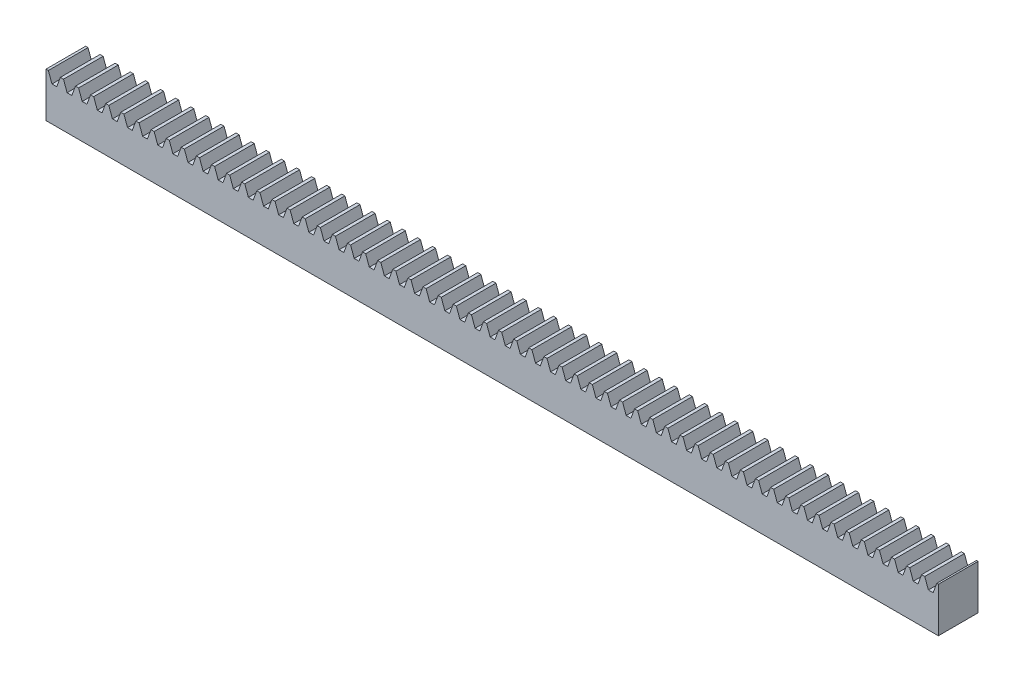
from build123d import *

# Parameters (mm, degrees)
SKETCH1_W           = 90
SKETCH1_H           = 4
BOSS_EXTRUDE1_DEPTH = 4.5
CUT_EXTRUDE1_DEPTH  = 5


with BuildPart() as part:
    # Sketch1 → Boss-Extrude1 (new body)
    with BuildSketch(Plane(origin=(0, 0, 0), x_dir=(1, 0, 0), z_dir=(0, 1, 0))):
        with Locations((45, 2)):
            Rectangle(SKETCH1_W, SKETCH1_H)
    extrude(amount=BOSS_EXTRUDE1_DEPTH)

    # Sketch2 → Cut-Extrude1 (cut, through all)
    with BuildSketch(Plane.XY):
        Polygon((0.239013956, 4.5), (0.60298419, 3.5), (0.841998146, 3.5), (1.081012101, 3.5), (1.444982335, 4.5), align=None)
        Polygon((1.763013956, 4.5), (2.12698419, 3.5), (2.365998146, 3.5), (2.605012101, 3.5), (2.968982335, 4.5), align=None)
        Polygon((3.287013956, 4.5), (3.65098419, 3.5), (3.889998146, 3.5), (4.129012101, 3.5), (4.492982335, 4.5), align=None)
        Polygon((4.811013956, 4.5), (5.17498419, 3.5), (5.413998146, 3.5), (5.653012101, 3.5), (6.016982335, 4.5), align=None)
        Polygon((6.335013956, 4.5), (6.69898419, 3.5), (6.937998146, 3.5), (7.177012101, 3.5), (7.540982335, 4.5), align=None)
        Polygon((7.859013956, 4.5), (8.22298419, 3.5), (8.461998146, 3.5), (8.701012101, 3.5), (9.064982335, 4.5), align=None)
        Polygon((9.383013956, 4.5), (9.74698419, 3.5), (9.985998146, 3.5), (10.225012101, 3.5), (10.588982335, 4.5), align=None)
        Polygon((10.907013956, 4.5), (11.27098419, 3.5), (11.509998146, 3.5), (11.749012101, 3.5), (12.112982335, 4.5), align=None)
        Polygon((12.431013956, 4.5), (12.79498419, 3.5), (13.033998146, 3.5), (13.273012101, 3.5), (13.636982335, 4.5), align=None)
        Polygon((13.955013956, 4.5), (14.31898419, 3.5), (14.557998146, 3.5), (14.797012101, 3.5), (15.160982335, 4.5), align=None)
        Polygon((15.479013956, 4.5), (15.84298419, 3.5), (16.081998146, 3.5), (16.321012101, 3.5), (16.684982335, 4.5), align=None)
        Polygon((17.003013956, 4.5), (17.36698419, 3.5), (17.605998146, 3.5), (17.845012101, 3.5), (18.208982335, 4.5), align=None)
        Polygon((18.527013956, 4.5), (18.89098419, 3.5), (19.129998146, 3.5), (19.369012101, 3.5), (19.732982335, 4.5), align=None)
        Polygon((20.051013956, 4.5), (20.41498419, 3.5), (20.653998146, 3.5), (20.893012101, 3.5), (21.256982335, 4.5), align=None)
        Polygon((21.575013956, 4.5), (21.93898419, 3.5), (22.177998146, 3.5), (22.417012101, 3.5), (22.780982335, 4.5), align=None)
        Polygon((23.099013956, 4.5), (23.46298419, 3.5), (23.701998146, 3.5), (23.941012101, 3.5), (24.304982335, 4.5), align=None)
        Polygon((24.623013956, 4.5), (24.98698419, 3.5), (25.225998146, 3.5), (25.465012101, 3.5), (25.828982335, 4.5), align=None)
        Polygon((26.147013956, 4.5), (26.51098419, 3.5), (26.749998146, 3.5), (26.989012101, 3.5), (27.352982335, 4.5), align=None)
        Polygon((27.671013956, 4.5), (28.03498419, 3.5), (28.273998146, 3.5), (28.513012101, 3.5), (28.876982335, 4.5), align=None)
        Polygon((29.195013956, 4.5), (29.55898419, 3.5), (29.797998146, 3.5), (30.037012101, 3.5), (30.400982335, 4.5), align=None)
        Polygon((30.719013956, 4.5), (31.08298419, 3.5), (31.321998146, 3.5), (31.561012101, 3.5), (31.924982335, 4.5), align=None)
        Polygon((32.243013956, 4.5), (32.60698419, 3.5), (32.845998146, 3.5), (33.085012101, 3.5), (33.448982335, 4.5), align=None)
        Polygon((33.767013956, 4.5), (34.13098419, 3.5), (34.369998146, 3.5), (34.609012101, 3.5), (34.972982335, 4.5), align=None)
        Polygon((35.291013956, 4.5), (35.65498419, 3.5), (35.893998146, 3.5), (36.133012101, 3.5), (36.496982335, 4.5), align=None)
        Polygon((36.815013956, 4.5), (37.17898419, 3.5), (37.417998146, 3.5), (37.657012101, 3.5), (38.020982335, 4.5), align=None)
        Polygon((38.339013956, 4.5), (38.70298419, 3.5), (38.941998146, 3.5), (39.181012101, 3.5), (39.544982335, 4.5), align=None)
        Polygon((39.863013956, 4.5), (40.22698419, 3.5), (40.465998146, 3.5), (40.705012101, 3.5), (41.068982335, 4.5), align=None)
        Polygon((41.387013956, 4.5), (41.75098419, 3.5), (41.989998146, 3.5), (42.229012101, 3.5), (42.592982335, 4.5), align=None)
        Polygon((42.911013956, 4.5), (43.27498419, 3.5), (43.513998146, 3.5), (43.753012101, 3.5), (44.116982335, 4.5), align=None)
        Polygon((44.435013956, 4.5), (44.79898419, 3.5), (45.037998146, 3.5), (45.277012101, 3.5), (45.640982335, 4.5), align=None)
        Polygon((45.959013956, 4.5), (46.32298419, 3.5), (46.561998146, 3.5), (46.801012101, 3.5), (47.164982335, 4.5), align=None)
        Polygon((47.483013956, 4.5), (47.84698419, 3.5), (48.085998146, 3.5), (48.325012101, 3.5), (48.688982335, 4.5), align=None)
        Polygon((49.007013956, 4.5), (49.37098419, 3.5), (49.609998146, 3.5), (49.849012101, 3.5), (50.212982335, 4.5), align=None)
        Polygon((50.531013956, 4.5), (50.89498419, 3.5), (51.133998146, 3.5), (51.373012101, 3.5), (51.736982335, 4.5), align=None)
        Polygon((52.055013956, 4.5), (52.41898419, 3.5), (52.657998146, 3.5), (52.897012101, 3.5), (53.260982335, 4.5), align=None)
        Polygon((53.579013956, 4.5), (53.94298419, 3.5), (54.181998146, 3.5), (54.421012101, 3.5), (54.784982335, 4.5), align=None)
        Polygon((55.103013956, 4.5), (55.46698419, 3.5), (55.705998146, 3.5), (55.945012101, 3.5), (56.308982335, 4.5), align=None)
        Polygon((56.627013956, 4.5), (56.99098419, 3.5), (57.229998146, 3.5), (57.469012101, 3.5), (57.832982335, 4.5), align=None)
        Polygon((58.151013956, 4.5), (58.51498419, 3.5), (58.753998146, 3.5), (58.993012101, 3.5), (59.356982335, 4.5), align=None)
        Polygon((59.675013956, 4.5), (60.03898419, 3.5), (60.277998146, 3.5), (60.517012101, 3.5), (60.880982335, 4.5), align=None)
        Polygon((61.199013956, 4.5), (61.56298419, 3.5), (61.801998146, 3.5), (62.041012101, 3.5), (62.404982335, 4.5), align=None)
        Polygon((62.723013956, 4.5), (63.08698419, 3.5), (63.325998146, 3.5), (63.565012101, 3.5), (63.928982335, 4.5), align=None)
        Polygon((64.247013956, 4.5), (64.61098419, 3.5), (64.849998146, 3.5), (65.089012101, 3.5), (65.452982335, 4.5), align=None)
        Polygon((65.771013956, 4.5), (66.13498419, 3.5), (66.373998146, 3.5), (66.613012101, 3.5), (66.976982335, 4.5), align=None)
        Polygon((67.295013956, 4.5), (67.65898419, 3.5), (67.897998146, 3.5), (68.137012101, 3.5), (68.500982335, 4.5), align=None)
        Polygon((68.819013956, 4.5), (69.18298419, 3.5), (69.421998146, 3.5), (69.661012101, 3.5), (70.024982335, 4.5), align=None)
        Polygon((70.343013956, 4.5), (70.70698419, 3.5), (70.945998146, 3.5), (71.185012101, 3.5), (71.548982335, 4.5), align=None)
        Polygon((71.867013956, 4.5), (72.23098419, 3.5), (72.469998146, 3.5), (72.709012101, 3.5), (73.072982335, 4.5), align=None)
        Polygon((73.391013956, 4.5), (73.75498419, 3.5), (73.993998146, 3.5), (74.233012101, 3.5), (74.596982335, 4.5), align=None)
        Polygon((74.915013956, 4.5), (75.27898419, 3.5), (75.517998146, 3.5), (75.757012101, 3.5), (76.120982335, 4.5), align=None)
        Polygon((76.439013956, 4.5), (76.80298419, 3.5), (77.041998146, 3.5), (77.281012101, 3.5), (77.644982335, 4.5), align=None)
        Polygon((77.963013956, 4.5), (78.32698419, 3.5), (78.565998146, 3.5), (78.805012101, 3.5), (79.168982335, 4.5), align=None)
        Polygon((79.487013956, 4.5), (79.85098419, 3.5), (80.089998146, 3.5), (80.329012101, 3.5), (80.692982335, 4.5), align=None)
        Polygon((81.011013956, 4.5), (81.37498419, 3.5), (81.613998146, 3.5), (81.853012101, 3.5), (82.216982335, 4.5), align=None)
        Polygon((82.535013956, 4.5), (82.89898419, 3.5), (83.137998146, 3.5), (83.377012101, 3.5), (83.740982335, 4.5), align=None)
        Polygon((84.059013956, 4.5), (84.42298419, 3.5), (84.661998146, 3.5), (84.901012101, 3.5), (85.264982335, 4.5), align=None)
        Polygon((85.583013956, 4.5), (85.94698419, 3.5), (86.185998146, 3.5), (86.425012101, 3.5), (86.788982335, 4.5), align=None)
        Polygon((87.107013956, 4.5), (87.47098419, 3.5), (87.709998146, 3.5), (87.949012101, 3.5), (88.312982335, 4.5), align=None)
        Polygon((88.631013956, 4.5), (88.99498419, 3.5), (89.233998146, 3.5), (89.473012101, 3.5), (89.836982335, 4.5), align=None)
        Polygon((90.155013956, 4.5), (90.51898419, 3.5), (90.757998146, 3.5), (90.997012101, 3.5), (91.360982335, 4.5), align=None)
        Polygon((91.679013956, 4.5), (92.04298419, 3.5), (92.281998146, 3.5), (92.521012101, 3.5), (92.884982335, 4.5), align=None)
        Polygon((93.203013956, 4.5), (93.56698419, 3.5), (93.805998146, 3.5), (94.045012101, 3.5), (94.408982335, 4.5), align=None)
        Polygon((94.727013956, 4.5), (95.09098419, 3.5), (95.329998146, 3.5), (95.569012101, 3.5), (95.932982335, 4.5), align=None)
        Polygon((96.251013956, 4.5), (96.61498419, 3.5), (96.853998146, 3.5), (97.093012101, 3.5), (97.456982335, 4.5), align=None)
        Polygon((97.775013956, 4.5), (98.13898419, 3.5), (98.377998146, 3.5), (98.617012101, 3.5), (98.980982335, 4.5), align=None)
        Polygon((99.299013956, 4.5), (99.66298419, 3.5), (99.901998146, 3.5), (100.141012101, 3.5), (100.504982335, 4.5), align=None)
        Polygon((100.823013956, 4.5), (101.18698419, 3.5), (101.425998146, 3.5), (101.665012101, 3.5), (102.028982335, 4.5), align=None)
        Polygon((102.347013956, 4.5), (102.71098419, 3.5), (102.949998146, 3.5), (103.189012101, 3.5), (103.552982335, 4.5), align=None)
        Polygon((103.871013956, 4.5), (104.23498419, 3.5), (104.473998146, 3.5), (104.713012101, 3.5), (105.076982335, 4.5), align=None)
        Polygon((105.395013956, 4.5), (105.75898419, 3.5), (105.997998146, 3.5), (106.237012101, 3.5), (106.600982335, 4.5), align=None)
        Polygon((106.919013956, 4.5), (107.28298419, 3.5), (107.521998146, 3.5), (107.761012101, 3.5), (108.124982335, 4.5), align=None)
        Polygon((108.443013956, 4.5), (108.80698419, 3.5), (109.045998146, 3.5), (109.285012101, 3.5), (109.648982335, 4.5), align=None)
        Polygon((109.967013956, 4.5), (110.33098419, 3.5), (110.569998146, 3.5), (110.809012101, 3.5), (111.172982335, 4.5), align=None)
        Polygon((111.491013956, 4.5), (111.85498419, 3.5), (112.093998146, 3.5), (112.333012101, 3.5), (112.696982335, 4.5), align=None)
        Polygon((113.015013956, 4.5), (113.37898419, 3.5), (113.617998146, 3.5), (113.857012101, 3.5), (114.220982335, 4.5), align=None)
        Polygon((114.539013956, 4.5), (114.90298419, 3.5), (115.141998146, 3.5), (115.381012101, 3.5), (115.744982335, 4.5), align=None)
        Polygon((116.063013956, 4.5), (116.42698419, 3.5), (116.665998146, 3.5), (116.905012101, 3.5), (117.268982335, 4.5), align=None)
        Polygon((117.587013956, 4.5), (117.95098419, 3.5), (118.189998146, 3.5), (118.429012101, 3.5), (118.792982335, 4.5), align=None)
        Polygon((119.111013956, 4.5), (119.47498419, 3.5), (119.713998146, 3.5), (119.953012101, 3.5), (120.316982335, 4.5), align=None)
        Polygon((120.635013956, 4.5), (120.99898419, 3.5), (121.237998146, 3.5), (121.477012101, 3.5), (121.840982335, 4.5), align=None)
        Polygon((122.159013956, 4.5), (122.52298419, 3.5), (122.761998146, 3.5), (123.001012101, 3.5), (123.364982335, 4.5), align=None)
        Polygon((123.683013956, 4.5), (124.04698419, 3.5), (124.285998146, 3.5), (124.525012101, 3.5), (124.888982335, 4.5), align=None)
        Polygon((125.207013956, 4.5), (125.57098419, 3.5), (125.809998146, 3.5), (126.049012101, 3.5), (126.412982335, 4.5), align=None)
        Polygon((126.731013956, 4.5), (127.09498419, 3.5), (127.333998146, 3.5), (127.573012101, 3.5), (127.936982335, 4.5), align=None)
        Polygon((128.255013956, 4.5), (128.61898419, 3.5), (128.857998146, 3.5), (129.097012101, 3.5), (129.460982335, 4.5), align=None)
        Polygon((129.779013956, 4.5), (130.14298419, 3.5), (130.381998146, 3.5), (130.621012101, 3.5), (130.984982335, 4.5), align=None)
        Polygon((131.303013956, 4.5), (131.66698419, 3.5), (131.905998146, 3.5), (132.145012101, 3.5), (132.508982335, 4.5), align=None)
        Polygon((132.827013956, 4.5), (133.19098419, 3.5), (133.429998146, 3.5), (133.669012101, 3.5), (134.032982335, 4.5), align=None)
        Polygon((134.351013956, 4.5), (134.71498419, 3.5), (134.953998146, 3.5), (135.193012101, 3.5), (135.556982335, 4.5), align=None)
        Polygon((135.875013956, 4.5), (136.23898419, 3.5), (136.477998146, 3.5), (136.717012101, 3.5), (137.080982335, 4.5), align=None)
        Polygon((137.399013956, 4.5), (137.76298419, 3.5), (138.001998146, 3.5), (138.241012101, 3.5), (138.604982335, 4.5), align=None)
        Polygon((138.923013956, 4.5), (139.28698419, 3.5), (139.525998146, 3.5), (139.765012101, 3.5), (140.128982335, 4.5), align=None)
        Polygon((140.447013956, 4.5), (140.81098419, 3.5), (141.049998146, 3.5), (141.289012101, 3.5), (141.652982335, 4.5), align=None)
        Polygon((141.971013956, 4.5), (142.33498419, 3.5), (142.573998146, 3.5), (142.813012101, 3.5), (143.176982335, 4.5), align=None)
        Polygon((143.495013956, 4.5), (143.85898419, 3.5), (144.097998146, 3.5), (144.337012101, 3.5), (144.700982335, 4.5), align=None)
        Polygon((145.019013956, 4.5), (145.38298419, 3.5), (145.621998146, 3.5), (145.861012101, 3.5), (146.224982335, 4.5), align=None)
        Polygon((146.543013956, 4.5), (146.90698419, 3.5), (147.145998146, 3.5), (147.385012101, 3.5), (147.748982335, 4.5), align=None)
        Polygon((148.067013956, 4.5), (148.43098419, 3.5), (148.669998146, 3.5), (148.909012101, 3.5), (149.272982335, 4.5), align=None)
        Polygon((149.591013956, 4.5), (149.95498419, 3.5), (150.193998146, 3.5), (150.433012101, 3.5), (150.796982335, 4.5), align=None)
        Polygon((151.115013956, 4.5), (151.47898419, 3.5), (151.717998146, 3.5), (151.957012101, 3.5), (152.320982335, 4.5), align=None)
        Polygon((152.639013956, 4.5), (153.00298419, 3.5), (153.241998146, 3.5), (153.481012101, 3.5), (153.844982335, 4.5), align=None)
        Polygon((154.163013956, 4.5), (154.52698419, 3.5), (154.765998146, 3.5), (155.005012101, 3.5), (155.368982335, 4.5), align=None)
        Polygon((155.687013956, 4.5), (156.05098419, 3.5), (156.289998146, 3.5), (156.529012101, 3.5), (156.892982335, 4.5), align=None)
        Polygon((157.211013956, 4.5), (157.57498419, 3.5), (157.813998146, 3.5), (158.053012101, 3.5), (158.416982335, 4.5), align=None)
        Polygon((158.735013956, 4.5), (159.09898419, 3.5), (159.337998146, 3.5), (159.577012101, 3.5), (159.940982335, 4.5), align=None)
        Polygon((160.259013956, 4.5), (160.62298419, 3.5), (160.861998146, 3.5), (161.101012101, 3.5), (161.464982335, 4.5), align=None)
        Polygon((161.783013956, 4.5), (162.14698419, 3.5), (162.385998146, 3.5), (162.625012101, 3.5), (162.988982335, 4.5), align=None)
        Polygon((163.307013956, 4.5), (163.67098419, 3.5), (163.909998146, 3.5), (164.149012101, 3.5), (164.512982335, 4.5), align=None)
        Polygon((164.831013956, 4.5), (165.19498419, 3.5), (165.433998146, 3.5), (165.673012101, 3.5), (166.036982335, 4.5), align=None)
        Polygon((166.355013956, 4.5), (166.71898419, 3.5), (166.957998146, 3.5), (167.197012101, 3.5), (167.560982335, 4.5), align=None)
        Polygon((167.879013956, 4.5), (168.24298419, 3.5), (168.481998146, 3.5), (168.721012101, 3.5), (169.084982335, 4.5), align=None)
        Polygon((169.403013956, 4.5), (169.76698419, 3.5), (170.005998146, 3.5), (170.245012101, 3.5), (170.608982335, 4.5), align=None)
        Polygon((170.927013956, 4.5), (171.29098419, 3.5), (171.529998146, 3.5), (171.769012101, 3.5), (172.132982335, 4.5), align=None)
        Polygon((172.451013956, 4.5), (172.81498419, 3.5), (173.053998146, 3.5), (173.293012101, 3.5), (173.656982335, 4.5), align=None)
        Polygon((173.975013956, 4.5), (174.33898419, 3.5), (174.577998146, 3.5), (174.817012101, 3.5), (175.180982335, 4.5), align=None)
        Polygon((175.499013956, 4.5), (175.86298419, 3.5), (176.101998146, 3.5), (176.341012101, 3.5), (176.704982335, 4.5), align=None)
        Polygon((177.023013956, 4.5), (177.38698419, 3.5), (177.625998146, 3.5), (177.865012101, 3.5), (178.228982335, 4.5), align=None)
        Polygon((178.547013956, 4.5), (178.91098419, 3.5), (179.149998146, 3.5), (179.389012101, 3.5), (179.752982335, 4.5), align=None)
        Polygon((180.071013956, 4.5), (180.43498419, 3.5), (180.673998146, 3.5), (180.913012101, 3.5), (181.276982335, 4.5), align=None)
        Polygon((181.595013956, 4.5), (181.95898419, 3.5), (182.197998146, 3.5), (182.437012101, 3.5), (182.800982335, 4.5), align=None)
        Polygon((183.119013956, 4.5), (183.48298419, 3.5), (183.721998146, 3.5), (183.961012101, 3.5), (184.324982335, 4.5), align=None)
        Polygon((184.643013956, 4.5), (185.00698419, 3.5), (185.245998146, 3.5), (185.485012101, 3.5), (185.848982335, 4.5), align=None)
        Polygon((186.167013956, 4.5), (186.53098419, 3.5), (186.769998146, 3.5), (187.009012101, 3.5), (187.372982335, 4.5), align=None)
        Polygon((187.691013956, 4.5), (188.05498419, 3.5), (188.293998146, 3.5), (188.533012101, 3.5), (188.896982335, 4.5), align=None)
        Polygon((189.215013956, 4.5), (189.57898419, 3.5), (189.817998146, 3.5), (190.057012101, 3.5), (190.420982335, 4.5), align=None)
    extrude(amount=-CUT_EXTRUDE1_DEPTH, mode=Mode.SUBTRACT)


solid = part.part
